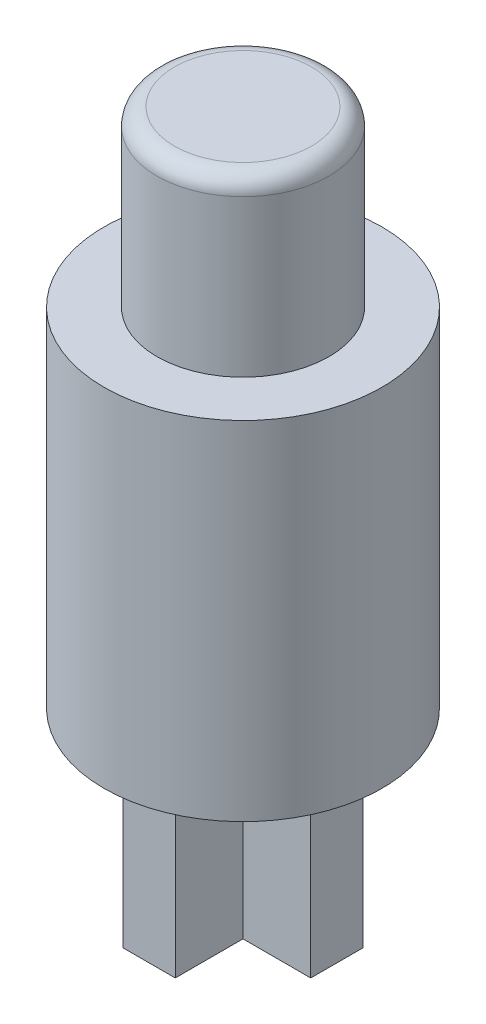
from build123d import *

# Parameters (mm, degrees)
SKETCH1_R           = 4
BOSS_EXTRUDE1_DEPTH = 10
SKETCH2_R           = 2.475
BOSS_EXTRUDE2_DEPTH = 5
SKETCH3_W           = 1.5
SKETCH3_H           = 5.4
SKETCH3_W_2         = 5.4
SKETCH3_H_2         = 1.5
BOSS_EXTRUDE3_DEPTH = 5
FILLET3_R           = 0.5


with BuildPart() as part:
    # Sketch1 → Boss-Extrude1 (new body)
    with BuildSketch(Plane(origin=(0, 0, 0), x_dir=(1, 0, 0), z_dir=(0, 1, 0))):
        Circle(SKETCH1_R)
    extrude(amount=-BOSS_EXTRUDE1_DEPTH)

    # Sketch2 → Boss-Extrude2 (add)
    with BuildSketch(Plane(origin=(0, 0, 0), x_dir=(1, 0, 0), z_dir=(0, 1, 0))):
        Circle(SKETCH2_R)
    extrude(amount=BOSS_EXTRUDE2_DEPTH)

    # Sketch3 → Boss-Extrude3 (add)
    with BuildSketch(Plane.XZ.offset(10)):
        Rectangle(SKETCH3_W, SKETCH3_H)
        Rectangle(SKETCH3_W_2, SKETCH3_H_2)
    extrude(amount=BOSS_EXTRUDE3_DEPTH)

    # Fillet3
    fillet3_edges = [part.edges().sort_by_distance(p)[0] for p in [
        (-2.475, 5, 0),
    ]]
    fillet(fillet3_edges, radius=FILLET3_R)


solid = part.part
